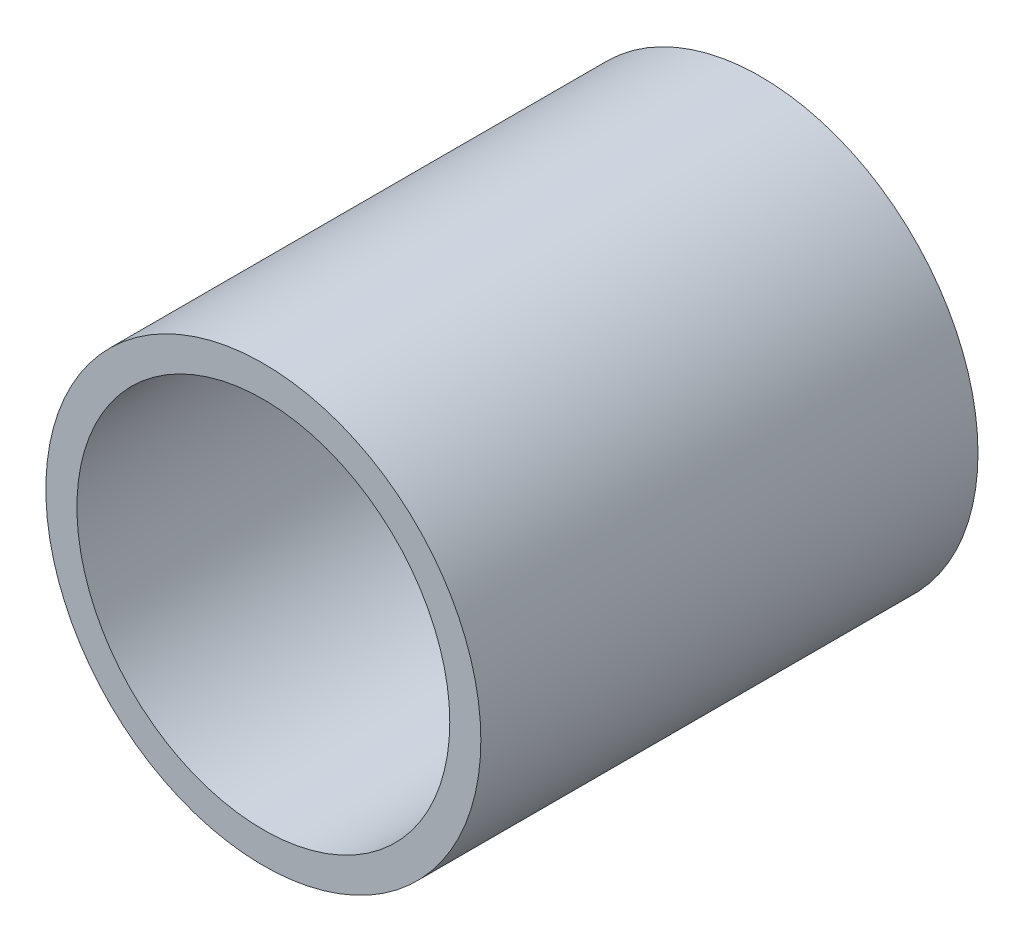
from build123d import *

# Parameters (mm, degrees)
SKETCH_1_R      = 1.75
SKETCH_1_R_2    = 1.5
EXTRUDE_1_DEPTH = 4


with BuildPart() as part:
    # 草图1 → 凸台-拉伸1 (new body)
    with BuildSketch(Plane.XY):
        Circle(SKETCH_1_R)
        Circle(SKETCH_1_R_2, mode=Mode.SUBTRACT)
    extrude(amount=EXTRUDE_1_DEPTH)


solid = part.part
